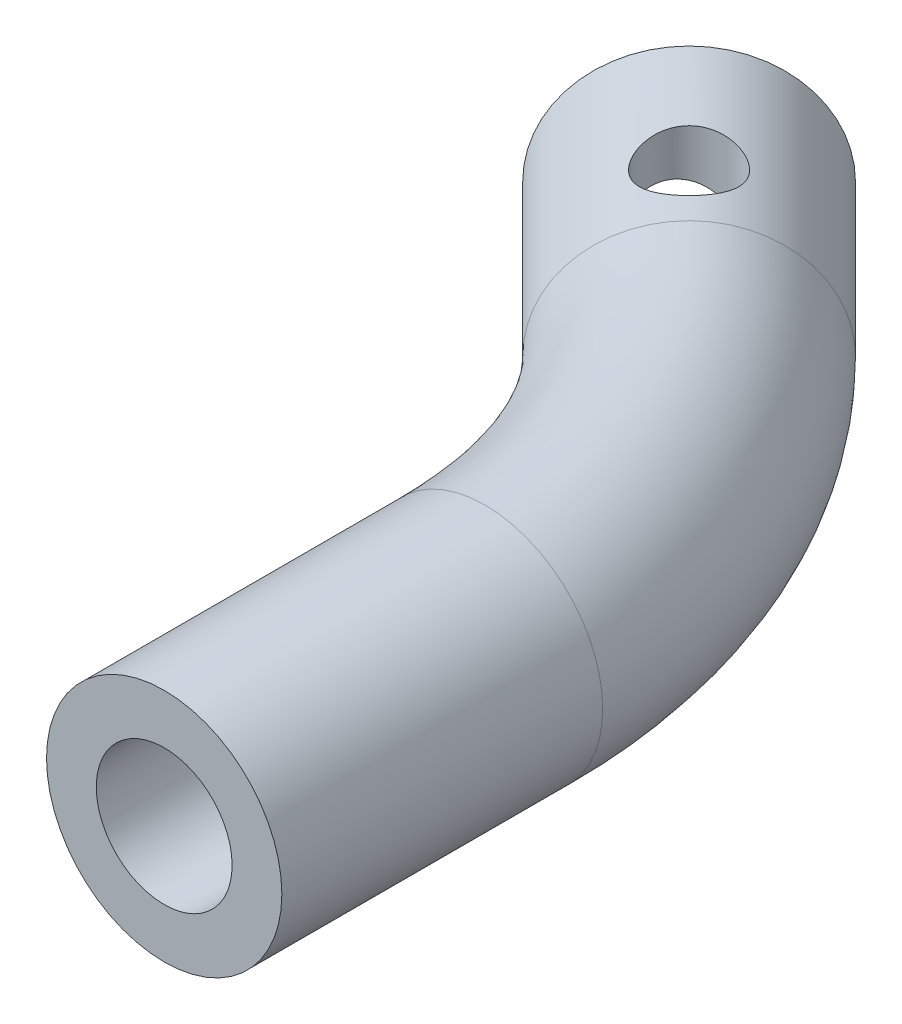
from build123d import *

# Parameters (mm, degrees)
SKETCH4_R           = 5.5
SKETCH6_R           = 3.175
HOLE_SHAFT_DEPTH    = 10
SKETCH7_R           = 3.4
HOLE_POT_DEPTH      = 10
SKETCH8_R           = 2
HOLE_INSERT_DEPTH   = 6.5000001
BOSS_EXTRUDE3_DEPTH = 1.5


with BuildPart() as part:
    # Sweep2: sweep along a path in PROFILE
    with BuildLine(Plane(origin=(0, 0, 0), x_dir=(1, 0, 0), z_dir=(0, 1, 0))) as sweep2_path:
        Line((2.5, -25), (2.5, -10))
        ThreePointArc((2.5, -10), (0.747502348, -1.189599343), (-4.243188728, 6.27949768))
        Line((-4.243188728, 6.27949768), (-11.31425654, 13.350565492))
    # Sketch4 → Sweep2 (sweep)
    with BuildSketch(Plane.XY.offset(25)):
        with Locations((2.5, 0)):
            Circle(SKETCH4_R)
    sweep(path=sweep2_path.line)

    # Sketch6 → HOLE_SHAFT (cut)
    with BuildSketch(Plane.XY.offset(25)):
        with Locations((2.5, 0)):
            Circle(SKETCH6_R)
    extrude(amount=-HOLE_SHAFT_DEPTH, mode=Mode.SUBTRACT)

    # Sketch7 → HOLE_POT (cut)
    with BuildSketch(Plane(origin=(-12.332411016, 0, -12.332411016), x_dir=(-0.707106781, 0, 0.707106781), z_dir=(-0.707106781, 0, -0.707106781))):
        with Locations((-0.57444604, 0)):
            Circle(SKETCH7_R)
    extrude(amount=-HOLE_POT_DEPTH, mode=Mode.SUBTRACT)

    # Sketch8 → HOLE_INSERT (cut, through all)
    with BuildSketch(Plane(origin=(0, 0, 0), x_dir=(1, 0, 0), z_dir=(0, 1, 0))):
        with Locations((-6.673561157, 8.709870109)):
            Circle(SKETCH8_R)
    extrude(amount=HOLE_INSERT_DEPTH, mode=Mode.SUBTRACT)

    # Sketch11 → Boss-Extrude3 (add)
    with BuildSketch(Plane(origin=(-5.261343204, 0, -5.261343204), x_dir=(-0.707106781, 0, 0.707106781), z_dir=(-0.707106781, 0, -0.707106781))):
        with BuildLine():
            Line((-0.905457853, 3.383848575), (0.72667763, -3.141190411))
            ThreePointArc((0.72667763, -3.141190411), (0.250591719, -3.298380314), (-0.243434227, -3.383848575))
            Line((-0.243434227, -3.383848575), (-1.87556971, 3.141190411))
            ThreePointArc((-1.87556971, 3.141190411), (-1.3994838, 3.298380314), (-0.905457853, 3.383848575))
        make_face()
    extrude(amount=BOSS_EXTRUDE3_DEPTH)


solid = part.part
